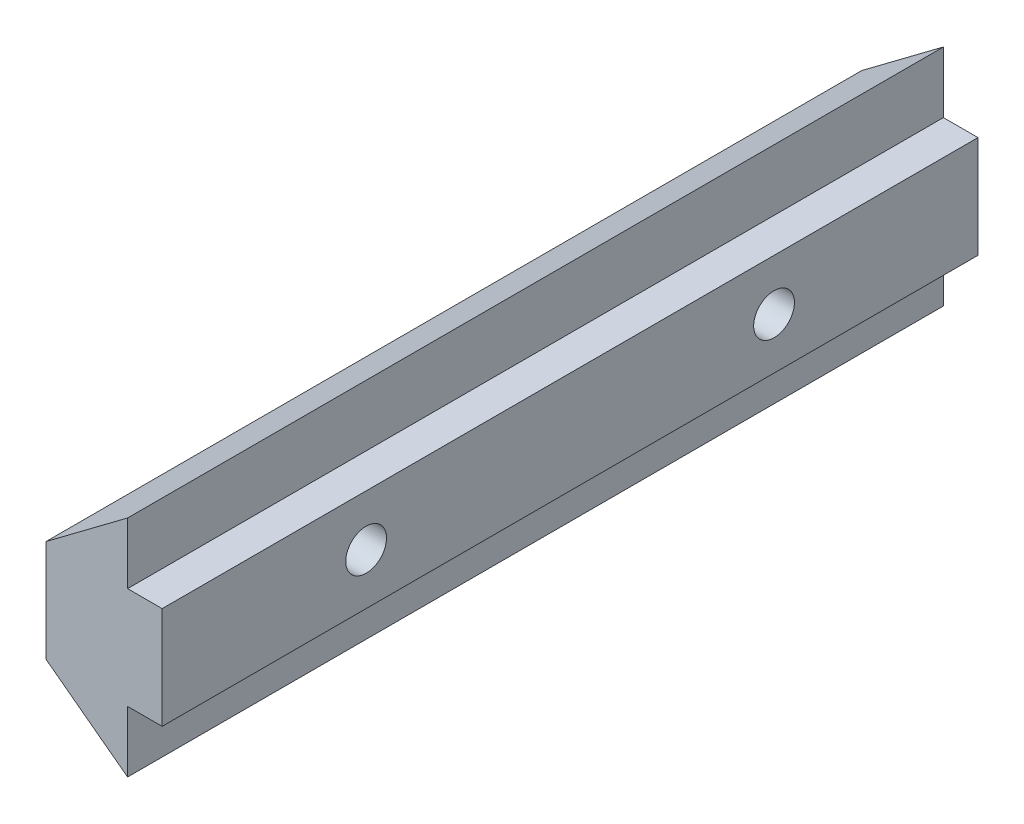
from build123d import *

# Parameters (mm, degrees)
BOSS_EXTRU_1_DEPTH         = 40
ESQUISSE1_R                = 1
ENL_V_MAT_EXTRU_1_DEPTH    = 6.695841166
R_P_TITION_LIN_AIRE2_COUNT = 2
R_P_TITION_LIN_AIRE2_PITCH = 20


with BuildPart() as part:
    # ProfileRainureEsquisse → Boss.-Extru.1 (new body)
    with BuildSketch(Plane.XY):
        Polygon((0, 0), (0, 5), (4, 8), (4, 5), (5.695841166, 5), (5.695841166, 0), (4, 0), (4, -3), align=None)
    extrude(amount=BOSS_EXTRU_1_DEPTH)

    # Esquisse1 → Enlèv. mat.-Extru.1 (cut, through all)
    with BuildSketch(Plane(origin=(5.695841166, 0, 0), x_dir=(0, 0, -1), z_dir=(1, 0, 0))):
        with Locations((-30, 2.5)):
            Circle(ESQUISSE1_R)
    enl_v_mat_extru_1 = extrude(amount=-ENL_V_MAT_EXTRU_1_DEPTH, mode=Mode.SUBTRACT)

    # Répétition linéaire2: Enlèv. mat.-Extru.1 ×2
    with Locations(*[(0, 0, -i * R_P_TITION_LIN_AIRE2_PITCH) for i in range(1, R_P_TITION_LIN_AIRE2_COUNT)]):
        add(enl_v_mat_extru_1, mode=Mode.SUBTRACT)


solid = part.part
